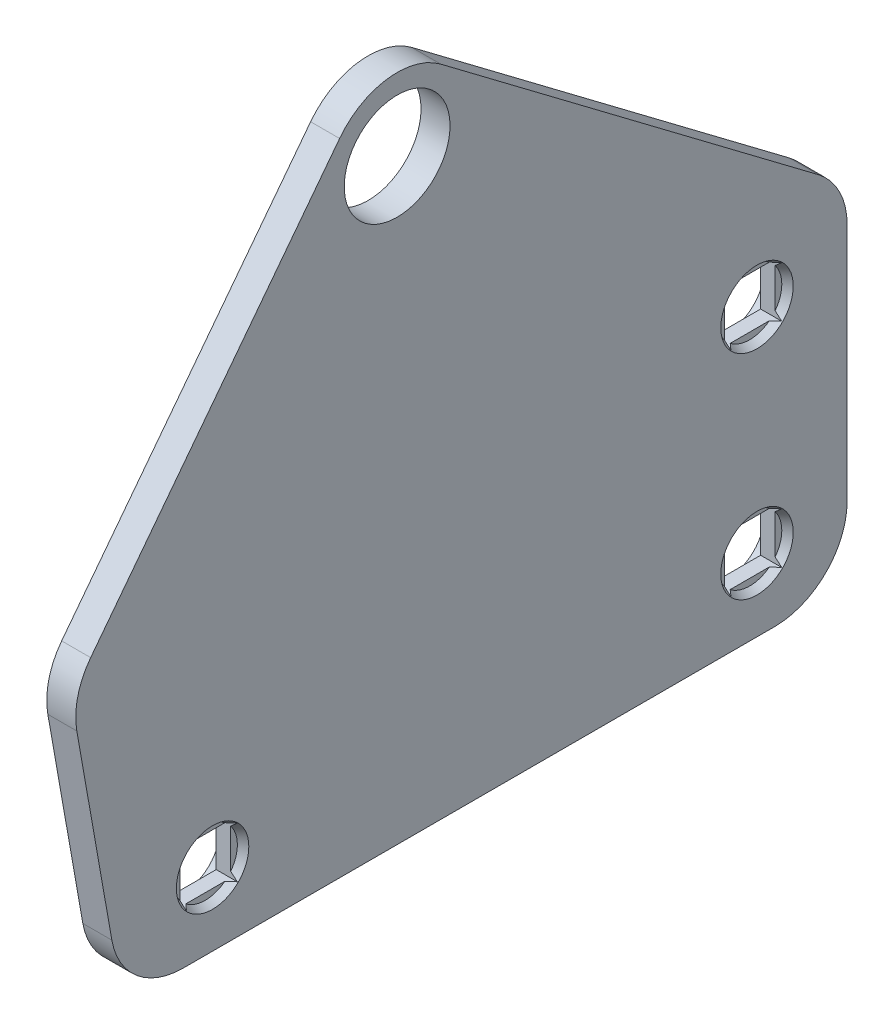
from build123d import *

# Parameters (mm, degrees)
SKETCH1_R           = 3.65
SKETCH1_W           = 3.5
SKETCH1_H           = 3.5
BOSS_EXTRUDE1_DEPTH = 2
SKETCH3_R           = 2.5
CUT_EXTRUDE1_DEPTH  = 0.5
CUT_EXTRUDE1_TAPER  = 30
SKETCH5_R           = 2.5
CUT_EXTRUDE2_DEPTH  = 0.5


with BuildPart() as part:
    # Sketch1 → Boss-Extrude1 (new body)
    with BuildSketch(Plane(origin=(0, 0, 0), x_dir=(0, 0, -1), z_dir=(1, 0, 0))):
        with BuildLine():
            Line((-20.402250922, 0), (20.402250922, 0))
            ThreePointArc((20.402250922, 0), (23.937784828, 1.464466094), (25.402250922, 5))
            Line((25.402250922, 5), (25.402250922, 21.50709196))
            ThreePointArc((25.402250922, 21.50709196), (24.87692273, 23.738081025), (23.411326038, 25.50026951))
            Line((23.411326038, 25.50026951), (-2.635195634, 45.127731407))
            ThreePointArc((-2.635195634, 45.127731407), (-6.321071977, 46.088536103), (-9.61416456, 44.174281334))
            Line((-9.61416456, 44.174281334), (-26.788641191, 21.74435991))
            ThreePointArc((-26.788641191, 21.74435991), (-27.676067974, 19.890565251), (-27.742786146, 17.836391544))
            Line((-27.742786146, 17.836391544), (-25.326289687, 4.131759112))
            ThreePointArc((-25.326289687, 4.131759112), (-23.61618897, 1.169777784), (-20.402250922, 0))
        make_face()
        with Locations((-5.64427075, 41.134553857)):
            Circle(SKETCH1_R, mode=Mode.SUBTRACT)
        with Locations((-18.377749078, 5)):
            Rectangle(SKETCH1_W, SKETCH1_H, mode=Mode.SUBTRACT)
        with Locations((19.182250922, 5)):
            Rectangle(SKETCH1_W, SKETCH1_H, mode=Mode.SUBTRACT)
        with Locations((19.182250922, 19.71162529)):
            Rectangle(SKETCH1_W, SKETCH1_H, mode=Mode.SUBTRACT)
    extrude(amount=BOSS_EXTRUDE1_DEPTH)

    # Sketch3 → Cut-Extrude1 (cut)
    with BuildSketch(Plane(origin=(2, 0, 0), x_dir=(0, 0, -1), z_dir=(1, 0, 0))):
        with Locations((-18.377749078, 5)):
            Circle(SKETCH3_R)
        with Locations((19.182250922, 5)):
            Circle(SKETCH3_R)
        with Locations((19.182250922, 19.712)):
            Circle(SKETCH3_R)
    extrude(amount=-CUT_EXTRUDE1_DEPTH, taper=CUT_EXTRUDE1_TAPER, mode=Mode.SUBTRACT)

    # Sketch5 → Cut-Extrude2 (cut)
    with BuildSketch(Plane.ZY):
        with Locations((-19.182250922, 5)):
            Circle(SKETCH5_R)
        with Locations((-19.182250922, 19.71162529)):
            Circle(SKETCH5_R)
        with Locations((18.377749078, 5)):
            Circle(SKETCH5_R)
    extrude(amount=-CUT_EXTRUDE2_DEPTH, mode=Mode.SUBTRACT)


solid = part.part
